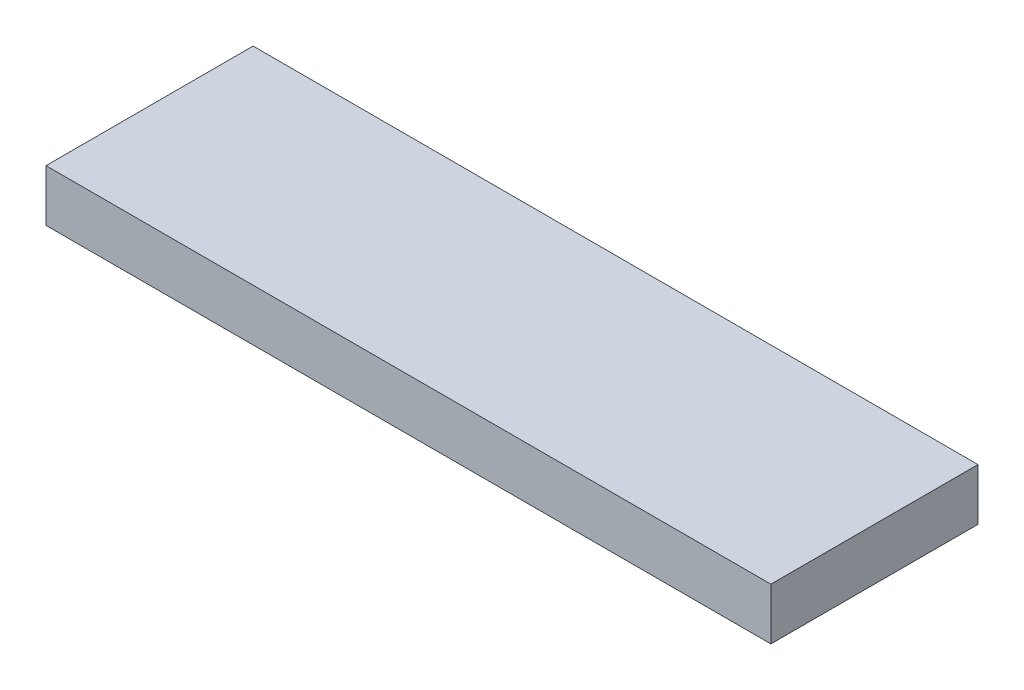
from build123d import *

# Parameters (mm, degrees)
SKETCH1_W      = 35.56
SKETCH1_H      = 10.16
EXTRUDE1_DEPTH = 2.54


with BuildPart() as part:
    # Sketch1 → Extrude1 (new body)
    with BuildSketch(Plane(origin=(0, 0, 0), x_dir=(1, 0, 0), z_dir=(0, 1, 0))):
        Rectangle(SKETCH1_W, SKETCH1_H)
    extrude(amount=EXTRUDE1_DEPTH)


solid = part.part
